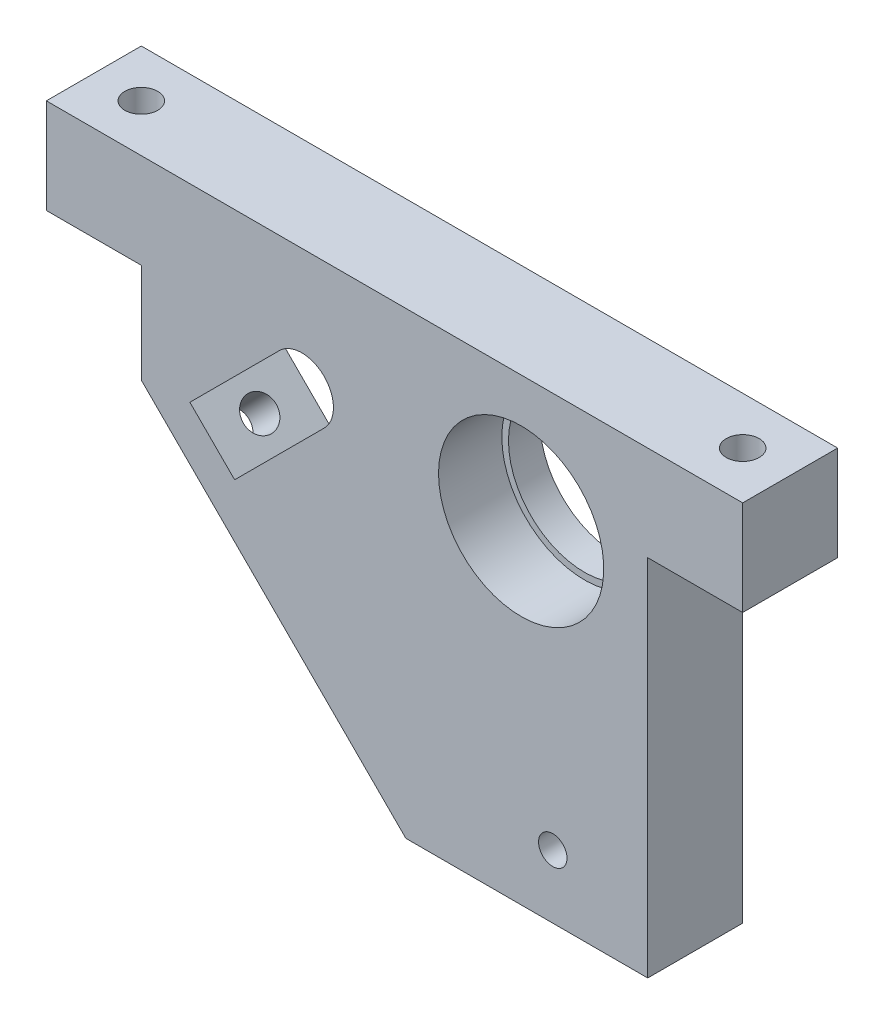
from build123d import *

# Parameters (mm, degrees)
SKETCH_1_R          = 12
SKETCH_1_R_2        = 2.25
EXTRUDE_1_DEPTH     = 15
SKETCH_2_R          = 13.05
CUT_EXTRUDE_1_DEPTH = 10
SKETCH_3_R          = 2.6
CUT_EXTRUDE_2_DEPTH = 73.5
SKETCH_5_R          = 2.6
CUT_EXTRUDE_3_DEPTH = 10


with BuildPart() as part:
    # 草图1 → 凸台-拉伸1 (new body)
    with BuildSketch(Plane.XY):
        Polygon((-33.800989673, 26.383498279), (-27.44059998, 26.383498279), (-18.800989673, 26.383498279), (-18.800989673, 10.67282016), (22.988332208, -31.116501721), (61.199010327, -31.116501721), (61.199010327, 26.383498279), (76.199010327, 26.383498279), (76.199010327, 41.383498279), (56.199010327, 41.383498279), (-33.800989673, 41.383498279), align=None)
        with Locations((41.199010327, 21.383498279)):
            Circle(SKETCH_1_R, mode=Mode.SUBTRACT)
        with Locations((46.199010327, -21.116501721)):
            Circle(SKETCH_1_R_2, mode=Mode.SUBTRACT)
        with BuildLine():
            Line((-11.126891481, 11.484003342), (3.015244143, 25.626138966))
            ThreePointArc((3.015244143, 25.626138966), (10.086311955, 25.626138966), (10.086311955, 18.555071154))
            Line((10.086311955, 18.555071154), (-4.055823669, 4.41293553))
            Line((-4.055823669, 4.41293553), (-11.126891481, 11.484003342))
        make_face(mode=Mode.SUBTRACT)
    extrude(amount=EXTRUDE_1_DEPTH)

    # 草图2 → 切除-拉伸1 (cut)
    with BuildSketch(Plane(origin=(0, 0, 15), x_dir=(-1, 0, 0), z_dir=(0, 0, -1))):
        with Locations((-41.199010327, 21.383498279)):
            Circle(SKETCH_2_R)
    extrude(amount=CUT_EXTRUDE_1_DEPTH, mode=Mode.SUBTRACT)

    # 草图3 → 切除-拉伸2 (cut, through all)
    with BuildSketch(Plane(origin=(0, 41.383498279, 0), x_dir=(1, 0, 0), z_dir=(0, 1, 0))):
        with Locations((-26.300989673, -7.5)):
            Circle(SKETCH_3_R)
        with Locations((68.699010327, -7.5)):
            Circle(SKETCH_3_R)
    extrude(amount=-CUT_EXTRUDE_2_DEPTH, mode=Mode.SUBTRACT)

    # 草图5 → 切除-拉伸3 (cut)
    with BuildSketch(Plane(origin=(-4.064084756, -4.064084756, 0), x_dir=(0, 0, 1), z_dir=(-0.707106781, -0.707106781, 0))):
        with Locations((7.5, 10.9911308)):
            Circle(SKETCH_5_R)
    extrude(amount=-CUT_EXTRUDE_3_DEPTH, mode=Mode.SUBTRACT)


solid = part.part
